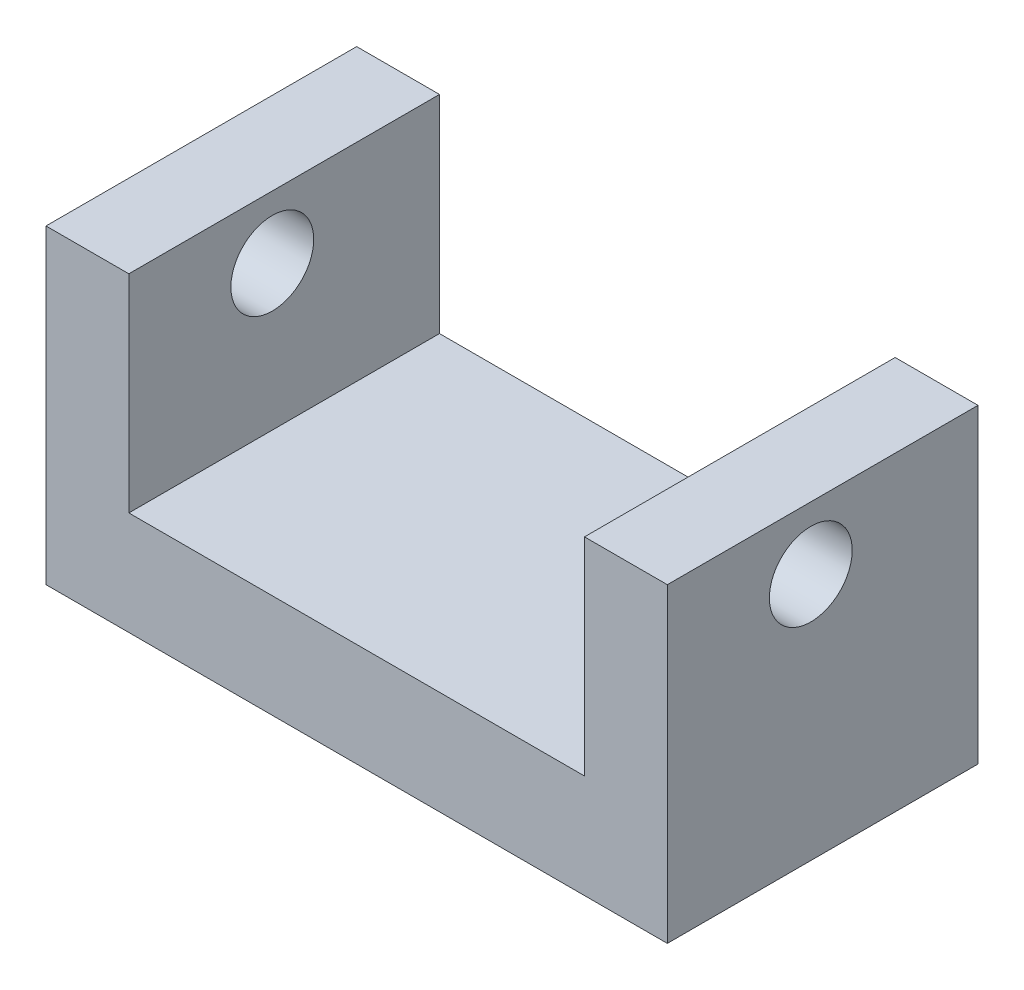
from build123d import *

# Parameters (mm, degrees)
BOSS_EXTRUDE1_DEPTH = 75
SKETCH2_R           = 10
CUT_EXTRUDE1_DEPTH  = 151


with BuildPart() as part:
    # Sketch1 → Boss-Extrude1 (new body)
    with BuildSketch(Plane.XY):
        Polygon((0, 0), (0, 75), (20, 75), (20, 25), (130, 25), (130, 75), (150, 75), (150, 0), align=None)
    extrude(amount=BOSS_EXTRUDE1_DEPTH)

    # Sketch2 → Cut-Extrude1 (cut, through all)
    with BuildSketch(Plane(origin=(150, 0, 0), x_dir=(0, 0, -1), z_dir=(1, 0, 0))):
        with Locations((-40.368725444, 59.887136839)):
            Circle(SKETCH2_R)
    extrude(amount=-CUT_EXTRUDE1_DEPTH, mode=Mode.SUBTRACT)


solid = part.part
